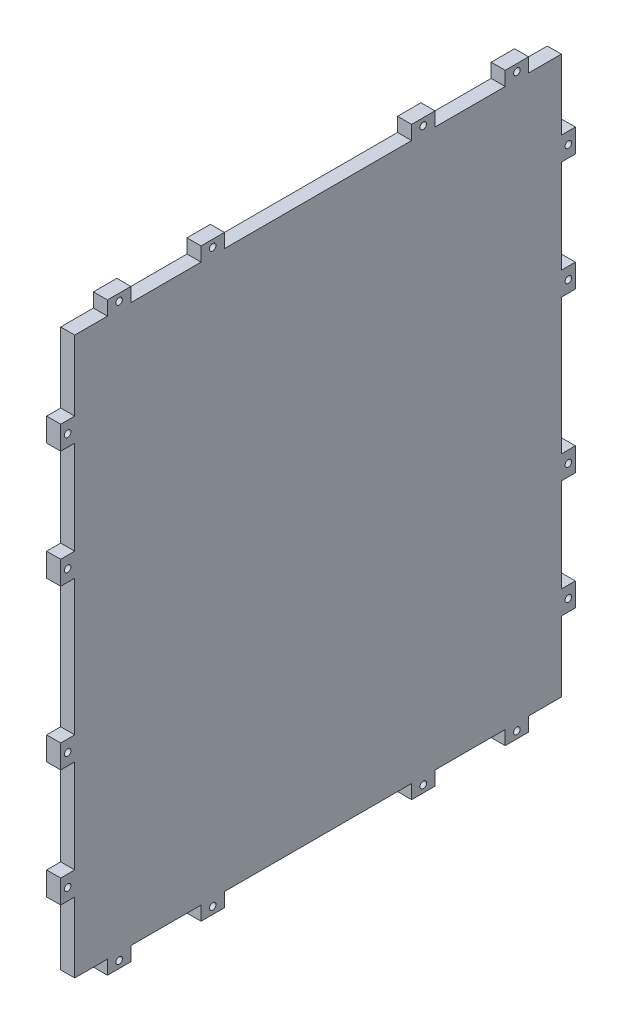
from build123d import *

# Parameters (mm, degrees)
ESQUISSE1_W             = 208
ESQUISSE1_H             = 238
BOSS_EXTRU_1_DEPTH      = 6
ESQUISSE3_W             = 10
ESQUISSE3_H             = 6
ESQUISSE3_W_2           = 6
ESQUISSE3_H_2           = 10
BOSS_EXTRU_5_DEPTH      = 6
ESQUISSE4_R             = 1.4
ENL_V_MAT_EXTRU_1_DEPTH = 6


with BuildPart() as part:
    # Esquisse1 → Boss.-Extru.1 (new body)
    with BuildSketch(Plane(origin=(0, 0, 0), x_dir=(0, 0, -1), z_dir=(1, 0, 0))):
        Rectangle(ESQUISSE1_W, ESQUISSE1_H)
    extrude(amount=BOSS_EXTRU_1_DEPTH)

    # Esquisse3 → Boss.-Extru.5 (add)
    with BuildSketch(Plane(origin=(6, 0, 0), x_dir=(0, 0, -1), z_dir=(1, 0, 0))):
        with Locations((-85, -122)):
            Rectangle(ESQUISSE3_W, ESQUISSE3_H)
        with Locations((-45, -122)):
            Rectangle(ESQUISSE3_W, ESQUISSE3_H)
        with Locations((107, -34)):
            Rectangle(ESQUISSE3_W_2, ESQUISSE3_H_2)
        with Locations((-107, -84)):
            Rectangle(ESQUISSE3_W_2, ESQUISSE3_H_2)
        with Locations((-107, -34)):
            Rectangle(ESQUISSE3_W_2, ESQUISSE3_H_2)
        with Locations((107, -84)):
            Rectangle(ESQUISSE3_W_2, ESQUISSE3_H_2)
        with Locations((45, -122)):
            Rectangle(ESQUISSE3_W, ESQUISSE3_H)
        with Locations((85, -122)):
            Rectangle(ESQUISSE3_W, ESQUISSE3_H)
        with Locations((85, 122)):
            Rectangle(ESQUISSE3_W, ESQUISSE3_H)
        with Locations((45, 122)):
            Rectangle(ESQUISSE3_W, ESQUISSE3_H)
        with Locations((107, 84)):
            Rectangle(ESQUISSE3_W_2, ESQUISSE3_H_2)
        with Locations((107, 34)):
            Rectangle(ESQUISSE3_W_2, ESQUISSE3_H_2)
        with Locations((-107, 34)):
            Rectangle(ESQUISSE3_W_2, ESQUISSE3_H_2)
        with Locations((-107, 84)):
            Rectangle(ESQUISSE3_W_2, ESQUISSE3_H_2)
        with Locations((-45, 122)):
            Rectangle(ESQUISSE3_W, ESQUISSE3_H)
        with Locations((-85, 122)):
            Rectangle(ESQUISSE3_W, ESQUISSE3_H)
    extrude(amount=-BOSS_EXTRU_5_DEPTH)

    # Esquisse4 → Enlèv. mat.-Extru.1 (cut)
    with BuildSketch(Plane(origin=(6, 0, 0), x_dir=(0, 0, -1), z_dir=(1, 0, 0))):
        with Locations((-85, 122)):
            Circle(ESQUISSE4_R)
        with Locations((-45, 122)):
            Circle(ESQUISSE4_R)
        with Locations((-107, 84)):
            Circle(ESQUISSE4_R)
        with Locations((-107, 34)):
            Circle(ESQUISSE4_R)
        with Locations((107, 34)):
            Circle(ESQUISSE4_R)
        with Locations((107, 84)):
            Circle(ESQUISSE4_R)
        with Locations((45, 122)):
            Circle(ESQUISSE4_R)
        with Locations((85, 122)):
            Circle(ESQUISSE4_R)
        with Locations((85, -122)):
            Circle(ESQUISSE4_R)
        with Locations((45, -122)):
            Circle(ESQUISSE4_R)
        with Locations((107, -84)):
            Circle(ESQUISSE4_R)
        with Locations((107, -34)):
            Circle(ESQUISSE4_R)
        with Locations((-107, -34)):
            Circle(ESQUISSE4_R)
        with Locations((-107, -84)):
            Circle(ESQUISSE4_R)
        with Locations((-45, -122)):
            Circle(ESQUISSE4_R)
        with Locations((-85, -122)):
            Circle(ESQUISSE4_R)
    extrude(amount=-ENL_V_MAT_EXTRU_1_DEPTH, mode=Mode.SUBTRACT)


solid = part.part
